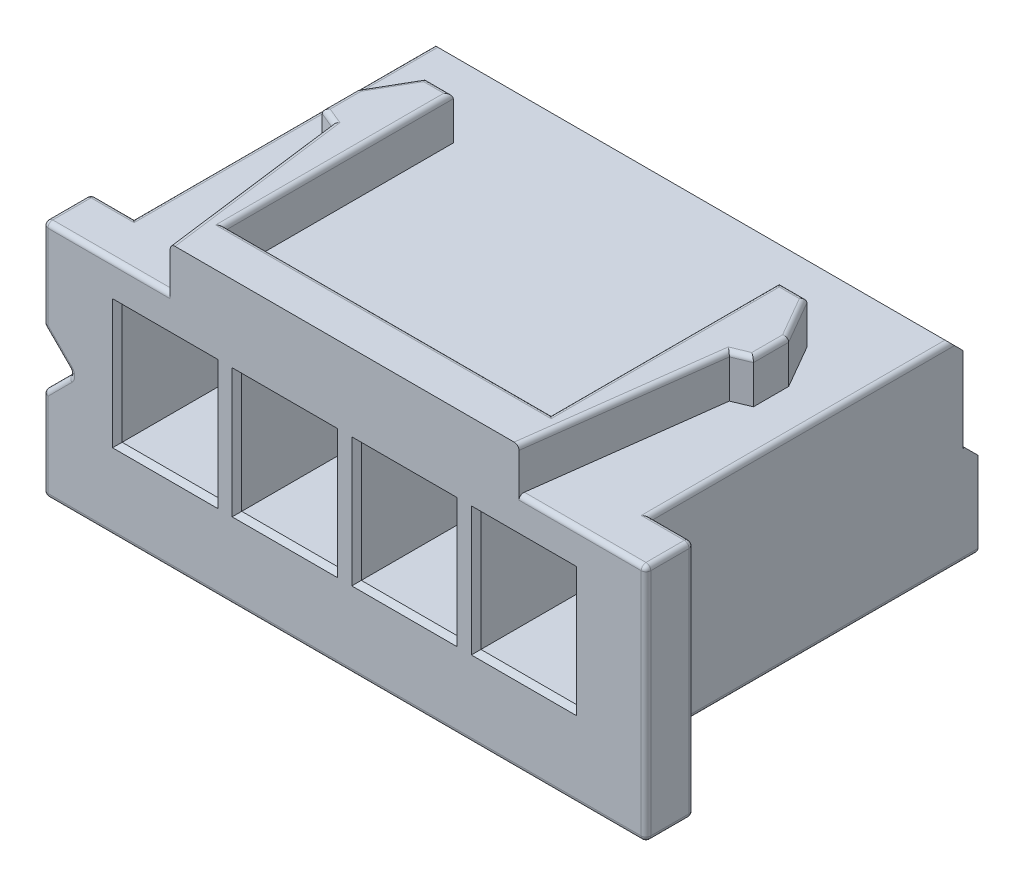
from build123d import *

# Parameters (mm, degrees)
BOSS_EXTRUDE1_DEPTH = 10.8
BOSS_EXTRUDE2_DEPTH = 1
BOSS_EXTRUDE3_DEPTH = 0.9
SKETCH5_W           = 2
SKETCH5_H           = 2.5
CUT_EXTRUDE1_DEPTH  = 5.2
CUT_EXTRUDE2_DEPTH  = 3.75
SKETCH7_W           = 1
SKETCH7_H           = 1
CUT_EXTRUDE3_DEPTH  = 2.5
FILLET1_R           = 0.1
CHAMFER1_SIZE       = 0.1


with BuildPart() as part:
    # Sketch2 → Boss-Extrude1 (new body)
    with BuildSketch(Plane(origin=(0, 0, 0), x_dir=(0, 0, -1), z_dir=(1, 0, 0))):
        Polygon((0, 4.116746825), (6.25, 4.116746825), (6.53, 3.836746825), (6.53, 2.066746825), (6.56, 2.066746825), (6.84, 1.786746825), (6.84, 0), (0, 0), align=None)
    extrude(amount=BOSS_EXTRUDE1_DEPTH)

    # Sketch3 → Boss-Extrude2 (add)
    with BuildSketch(Plane.XY):
        Polygon((-0.9, 1.016746825), (-0.9, -0.883253175), (11.7, -0.883253175), (11.7, 4.116746825), (-0.9, 4.116746825), (-0.9, 2.216746825), (-0.3, 1.616746825), align=None)
    extrude(amount=BOSS_EXTRUDE2_DEPTH)

    # Sketch4 → Boss-Extrude3 (add)
    with BuildSketch(Plane(origin=(0, 4.116746825, 0), x_dir=(1, 0, 0), z_dir=(0, 1, 0))):
        Polygon((1.249253009, 2.891399382), (0.893756458, 3.03935436), (0.893756458, 3.77625502), (1.41465396, 4.678475961), (1.993020778, 4.678475961), (1.993020778, -0.09), (8.806979222, -0.09), (8.806979222, 4.678475961), (9.38534604, 4.678475961), (9.906243542, 3.77625502), (9.906243542, 3.03935436), (9.550746991, 2.891399382), (9.045115198, -1), (1.754884802, -1), align=None)
    extrude(amount=BOSS_EXTRUDE3_DEPTH)

    # Sketch5 → Cut-Extrude1 (cut)
    with BuildSketch(Plane.XY.offset(1)):
        with Locations((1.65, 2.066746825)):
            Rectangle(SKETCH5_W, SKETCH5_H)
        with Locations((4.15, 2.066746825)):
            Rectangle(SKETCH5_W, SKETCH5_H)
        with Locations((6.65, 2.066746825)):
            Rectangle(SKETCH5_W, SKETCH5_H)
        with Locations((9.15, 2.066746825)):
            Rectangle(SKETCH5_W, SKETCH5_H)
    extrude(amount=-CUT_EXTRUDE1_DEPTH, mode=Mode.SUBTRACT)

    # Sketch6 → Cut-Extrude2 (cut)
    with BuildSketch(Plane(origin=(0, 0, -6.84), x_dir=(-1, 0, 0), z_dir=(0, 0, -1))):
        Polygon((-9.55, 0.8), (-8.75, 0.8), (-8.55, 0), (-9.75, 0), align=None)
        Polygon((-7.05, 0.8), (-6.25, 0.8), (-6.05, 0), (-7.25, 0), align=None)
        Polygon((-4.55, 0.8), (-3.75, 0.8), (-3.55, 0), (-4.75, 0), align=None)
        Polygon((-2.05, 0.8), (-1.25, 0.8), (-1.05, 0), (-2.25, 0), align=None)
    extrude(amount=-CUT_EXTRUDE2_DEPTH, mode=Mode.SUBTRACT)

    # Sketch7 → Cut-Extrude3 (cut)
    with BuildSketch(Plane(origin=(0, 0, -6.53), x_dir=(-1, 0, 0), z_dir=(0, 0, -1))):
        with Locations((-9.15, 2.836746825)):
            Rectangle(SKETCH7_W, SKETCH7_H)
        with Locations((-6.65, 2.836746825)):
            Rectangle(SKETCH7_W, SKETCH7_H)
        with Locations((-4.15, 2.836746825)):
            Rectangle(SKETCH7_W, SKETCH7_H)
        with Locations((-1.65, 2.836746825)):
            Rectangle(SKETCH7_W, SKETCH7_H)
    extrude(amount=-CUT_EXTRUDE3_DEPTH, mode=Mode.SUBTRACT)

    # Fillet1
    fillet1_edges = [part.edges().sort_by_distance(p)[0] for p in [
        (9.297931094, 5.016746825, -0.945699691),
        (9.728495267, 5.016746825, -2.965376871),
        (9.906243542, 5.016746825, -3.40780469),
        (9.645794791, 5.016746825, -4.22736549),
        (9.096162631, 5.016746825, -4.678475961),
        (8.806979222, 5.016746825, -2.29423798),
        (5.4, 5.016746825, 0.09),
        (1.993020778, 5.016746825, -2.29423798),
        (1.703837369, 5.016746825, -4.678475961),
        (1.154205209, 5.016746825, -4.22736549),
        (0.893756458, 5.016746825, -3.40780469),
        (1.071504733, 5.016746825, -2.965376871),
        (1.502068906, 5.016746825, -0.945699691),
        (-0.6, 1.916746825, 0),
        (-0.6, 1.316746825, 1),
        (0, 0, -3.42),
        (0, 4.116746825, -3.125),
        (10.8, 0, -3.42),
        (-0.45, 4.116746825, 0),
        (-0.9, 3.166746825, 0),
        (-0.6, 1.316746825, 0),
        (-0.9, 0.066746825, 0),
        (5.4, -0.883253175, 0),
        (11.25, 4.116746825, 0),
        (11.7, 1.616746825, 0),
        (10.372557599, 4.116746825, 1),
        (-0.9, 0.066746825, 1),
        (-0.6, 1.916746825, 1),
        (-0.9, 3.166746825, 1),
        (0.427442401, 4.116746825, 1),
        (5.4, -0.883253175, 1),
        (11.7, 1.616746825, 1),
        (-0.3, 1.616746825, 0.5),
        (-0.9, 1.016746825, 0.5),
        (-0.9, 2.216746825, 0.5),
        (-0.9, 4.116746825, 0.5),
        (-0.9, -0.883253175, 0.5),
        (11.7, -0.883253175, 0.5),
        (10.8, 4.116746825, -3.125),
        (11.7, 4.116746825, 0.5),
        (0.525, 0, -6.84),
        (2.9, 0, -6.84),
        (5.4, 0, -6.84),
        (7.9, 0, -6.84),
        (10.275, 0, -6.84),
    ]]
    fillet(fillet1_edges, radius=FILLET1_R)

    # Chamfer1
    chamfer1_edges = [part.edges().sort_by_distance(p)[0] for p in [
        (3.15, 2.066746825, 1),
        (4.15, 0.816746825, 1),
        (5.15, 2.066746825, 1),
        (4.15, 3.316746825, 1),
        (5.65, 2.066746825, 1),
        (6.65, 0.816746825, 1),
        (7.65, 2.066746825, 1),
        (6.65, 3.316746825, 1),
        (8.15, 2.066746825, 1),
        (9.15, 0.816746825, 1),
        (10.15, 2.066746825, 1),
        (9.15, 3.316746825, 1),
        (9.65, 2.836746825, -6.53),
        (9.15, 2.336746825, -6.53),
        (8.65, 2.836746825, -6.53),
        (9.15, 3.336746825, -6.53),
        (7.15, 2.836746825, -6.53),
        (6.65, 2.336746825, -6.53),
        (6.15, 2.836746825, -6.53),
        (6.65, 3.336746825, -6.53),
        (4.65, 2.836746825, -6.53),
        (4.15, 2.336746825, -6.53),
        (3.65, 2.836746825, -6.53),
        (4.15, 3.336746825, -6.53),
        (2.15, 2.836746825, -6.53),
        (1.65, 2.336746825, -6.53),
        (1.15, 2.836746825, -6.53),
        (1.65, 3.336746825, -6.53),
        (0.65, 2.066746825, 1),
        (1.65, 0.816746825, 1),
        (2.65, 2.066746825, 1),
        (1.65, 3.316746825, 1),
    ]]
    chamfer(chamfer1_edges, length=CHAMFER1_SIZE)


solid = part.part
